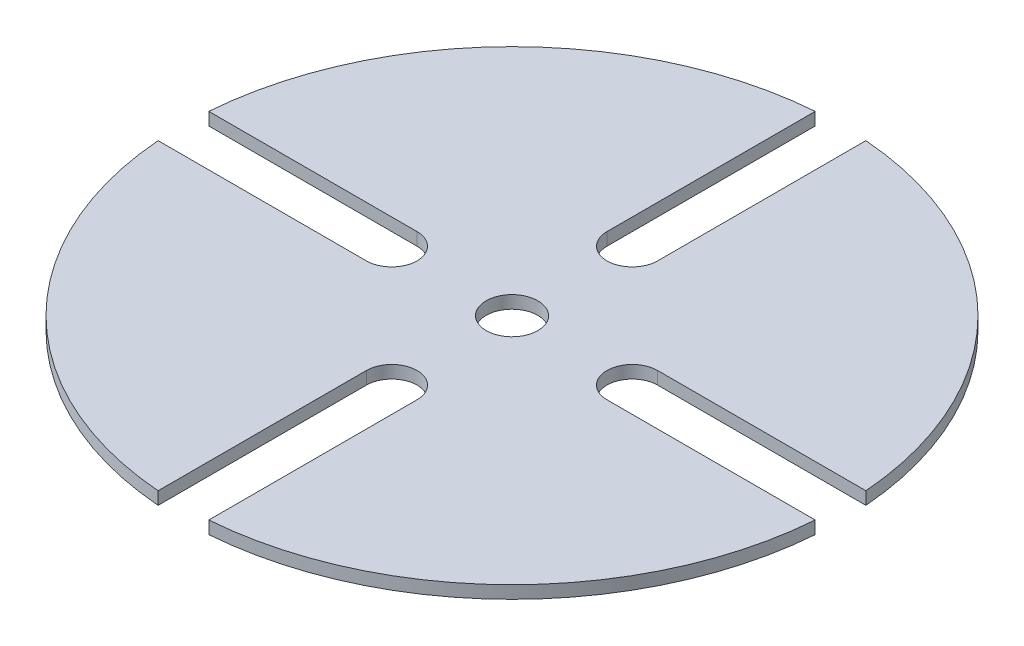
from build123d import *

# Parameters (mm, degrees)
BOSS_EXTRUDE1_DEPTH = 3.175
CUT_EXTRUDE1_REACH  = 5.175
SKETCH5_R           = 6.477


with BuildPart() as part:
    # Sketch4 → Boss-Extrude1 (new body)
    with BuildSketch(Plane(origin=(0, 35.86734, 0), x_dir=(1, 0, 0), z_dir=(0, 1, 0))):
        with BuildLine():
            Line((-176.599307952, 6.35), (-124.425974424, 6.35))
            ThreePointArc((-124.425974424, 6.35), (-118.075974424, 0), (-124.425974424, -6.35))
            Line((-124.425974424, -6.35), (-176.599307952, -6.35))
            ThreePointArc((-176.599307952, -6.35), (-152.665565869, -58.371664787), (-100.643901082, -82.30540687))
            Line((-100.643901082, -82.30540687), (-100.643901082, -30.132073341))
            ThreePointArc((-100.643901082, -30.132073341), (-94.293901082, -23.782073341), (-87.943901082, -30.132073341))
            Line((-87.943901082, -30.132073341), (-87.943901082, -82.30540687))
            ThreePointArc((-87.943901082, -82.30540687), (-35.922236295, -58.371664787), (-11.988494212, -6.35))
            Line((-11.988494212, -6.35), (-64.161827741, -6.35))
            ThreePointArc((-64.161827741, -6.35), (-70.511827741, 0), (-64.161827741, 6.35))
            Line((-64.161827741, 6.35), (-11.988494212, 6.35))
            ThreePointArc((-11.988494212, 6.35), (-35.922236295, 58.371664787), (-87.943901082, 82.30540687))
            Line((-87.943901082, 82.30540687), (-87.943901082, 30.132073341))
            ThreePointArc((-87.943901082, 30.132073341), (-94.293901082, 23.782073341), (-100.643901082, 30.132073341))
            Line((-100.643901082, 30.132073341), (-100.643901082, 82.30540687))
            ThreePointArc((-100.643901082, 82.30540687), (-152.665565869, 58.371664787), (-176.599307952, 6.35))
        make_face()
    extrude(amount=BOSS_EXTRUDE1_DEPTH)

    # Sketch5 → Cut-Extrude1 (cut, up to next)
    with BuildSketch(Plane(origin=(0, 39.04234, 0), x_dir=(1, 0, 0), z_dir=(0, 1, 0)), mode=Mode.PRIVATE) as cut_extrude1_sk1:
        with Locations((-94.293901082, 0)):
            Circle(SKETCH5_R)
    cut_extrude1_tool1 = extrude(cut_extrude1_sk1.sketch, amount=-CUT_EXTRUDE1_REACH, mode=Mode.PRIVATE) & part.part
    add(cut_extrude1_tool1.solids().sort_by_distance((-94.293901, 39.04234, 0))[0], mode=Mode.SUBTRACT)


solid = part.part
